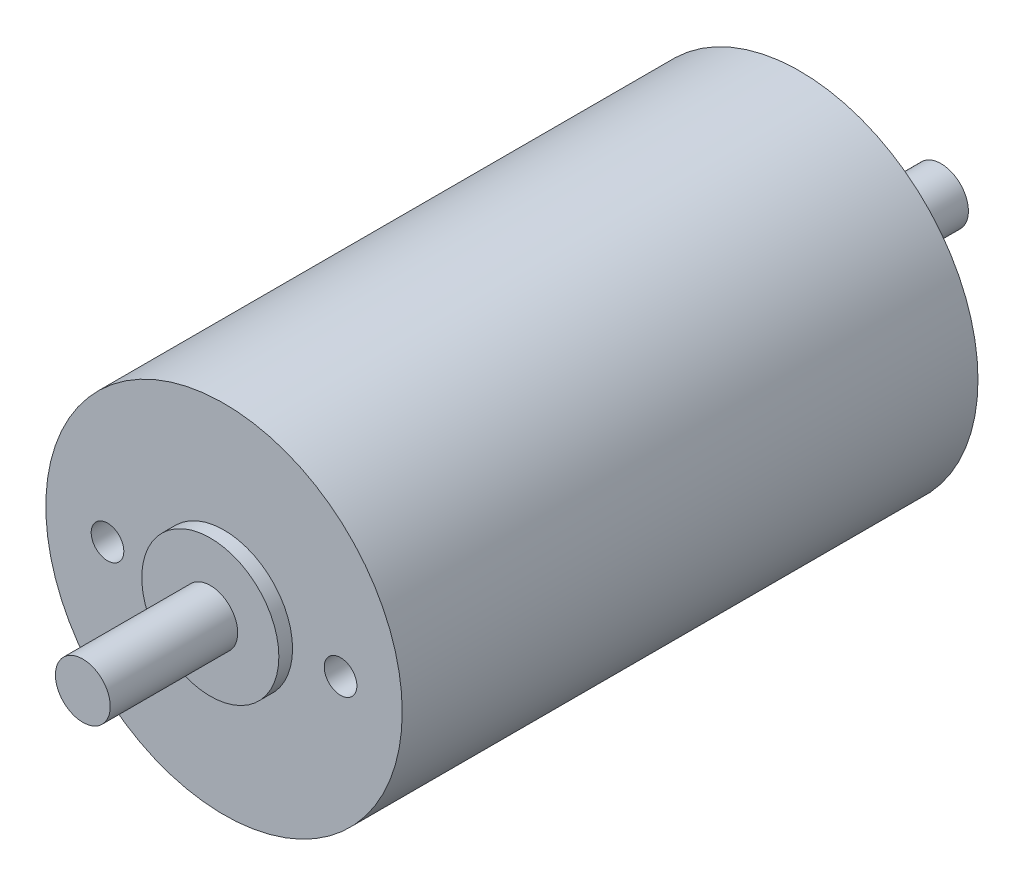
from build123d import *

# Parameters (mm, degrees)
SKETCH1_R                           = 13
BOSS_EXTRUDE1_DEPTH                 = 21
SKETCH2_R                           = 5
BOSS_EXTRUDE2_DEPTH                 = 1
SKETCH4_R                           = 5.5
BOSS_EXTRUDE4_DEPTH                 = 1
SKETCH3_R                           = 2
BOSS_EXTRUDE5_DEPTH                 = 9.3
SKETCH5_R                           = 2
BOSS_EXTRUDE6_DEPTH                 = 9.3
F_3_32_0_09375_DIAMETER_HOLE1_D     = 2.38125
F_3_32_0_09375_DIAMETER_HOLE1_DEPTH = 12.7
F_3_32_0_09375_DIAMETER_HOLE1_TIP   = 0.715399675


with BuildPart() as part:
    # Sketch1 → Boss-Extrude1 (new body, symmetric)
    with BuildSketch(Plane(origin=(0, 0, 0), x_dir=(0, 1, 0), z_dir=(0, 0, 1))):
        Circle(SKETCH1_R)
    extrude(amount=BOSS_EXTRUDE1_DEPTH, both=True)

    # Sketch2 → Boss-Extrude2 (add)
    with BuildSketch(Plane.XY.offset(21)):
        Circle(SKETCH2_R)
    extrude(amount=BOSS_EXTRUDE2_DEPTH)

    # Sketch4 → Boss-Extrude4 (add)
    with BuildSketch(Plane(origin=(0, 0, -21), x_dir=(1, 0, 0), z_dir=(0, 0, -1))):
        Circle(SKETCH4_R)
    extrude(amount=BOSS_EXTRUDE4_DEPTH)

    # Sketch3 → Boss-Extrude5 (add)
    with BuildSketch(Plane.XY.offset(22)):
        Circle(SKETCH3_R)
    extrude(amount=BOSS_EXTRUDE5_DEPTH)

    # Sketch5 → Boss-Extrude6 (add)
    with BuildSketch(Plane(origin=(0, 0, -22), x_dir=(1, 0, 0), z_dir=(0, 0, -1))):
        Circle(SKETCH5_R)
    extrude(amount=BOSS_EXTRUDE6_DEPTH)

    # 3/32 (0.09375) Diameter Hole1
    with Locations(Plane.XY.offset(21)):
        with Locations((8.5, 0), (-8.5, 0)):
            Hole(F_3_32_0_09375_DIAMETER_HOLE1_D / 2, depth=F_3_32_0_09375_DIAMETER_HOLE1_DEPTH)
            with Locations((0, 0, -(F_3_32_0_09375_DIAMETER_HOLE1_DEPTH + F_3_32_0_09375_DIAMETER_HOLE1_TIP / 2))):  # 118° drill point
                Cone(0, F_3_32_0_09375_DIAMETER_HOLE1_D / 2, F_3_32_0_09375_DIAMETER_HOLE1_TIP, mode=Mode.SUBTRACT)


solid = part.part
